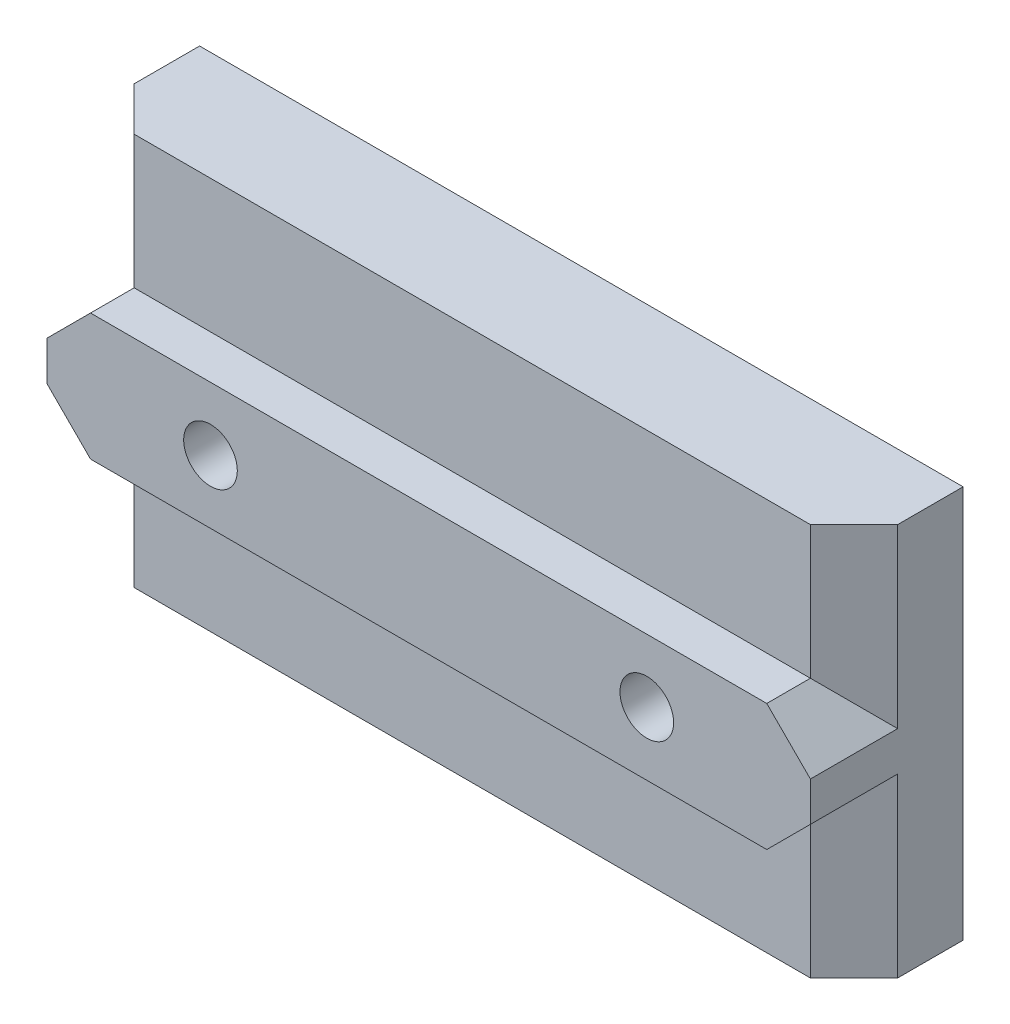
from build123d import *

# Parameters (mm, degrees)
SKETCH1_W                = 35
SKETCH1_H                = 18
BOSS_EXTRUDE1_DEPTH      = 8
SKETCH2_W                = 3
SKETCH2_H                = 6.1
CUT_EXTRUDE1_DEPTH       = 36
SKETCH3_W                = 3
SKETCH3_H                = 6.1
CUT_EXTRUDE2_DEPTH       = 36
M2_CLEARANCE_HOLE1_D     = 2.459
M2_CLEARANCE_HOLE1_DEPTH = 8
CHAMFER1_SIZE            = 0.2705
CHAMFER2_SIZE            = 2
SKETCH6_W                = 35
SKETCH6_H                = 1
CUT_EXTRUDE4_DEPTH       = 10


with BuildPart() as part:
    # Sketch1 → Boss-Extrude1 (new body)
    with BuildSketch(Plane.XY.offset(8)):
        Rectangle(SKETCH1_W, SKETCH1_H)
    extrude(amount=-BOSS_EXTRUDE1_DEPTH)

    # Sketch2 → Cut-Extrude1 (cut, through all)
    with BuildSketch(Plane.ZY.offset(17.5)):
        with Locations((6.5, 5.95)):
            Rectangle(SKETCH2_W, SKETCH2_H)
    extrude(amount=-CUT_EXTRUDE1_DEPTH, mode=Mode.SUBTRACT)

    # Sketch3 → Cut-Extrude2 (cut, through all)
    with BuildSketch(Plane.ZY.offset(17.5)):
        with Locations((6.5, -5.95)):
            Rectangle(SKETCH3_W, SKETCH3_H)
    extrude(amount=-CUT_EXTRUDE2_DEPTH, mode=Mode.SUBTRACT)

    # M2 Clearance Hole1
    with Locations(Plane.XY.offset(8)):
        with Locations((-10, 0), (10, 0)):
            Hole(M2_CLEARANCE_HOLE1_D / 2, depth=M2_CLEARANCE_HOLE1_DEPTH)

    # Chamfer1
    chamfer1_edges = [part.edges().sort_by_distance(p)[0] for p in [
        (11.2295, 0, 8),
        (11.2295, 0, 0),
        (-8.7705, 0, 8),
        (-8.7705, 0, 0),
    ]]
    chamfer(chamfer1_edges, length=CHAMFER1_SIZE)

    # Chamfer2
    chamfer2_edges = [part.edges().sort_by_distance(p)[0] for p in [
        (17.5, 5.95, 5),
        (17.5, 2.9, 6.5),
        (-17.5, 5.95, 5),
        (-17.5, 2.9, 6.5),
        (17.5, -5.95, 5),
        (17.5, -2.9, 6.5),
        (-17.5, -2.9, 6.5),
        (-17.5, -5.95, 5),
    ]]
    chamfer(chamfer2_edges, length=CHAMFER2_SIZE)

    # Sketch6 → Cut-Extrude4 (cut)
    with BuildSketch(Plane(origin=(0, 2.9, 0), x_dir=(1, 0, 0), z_dir=(0, 1, 0))):
        with Locations((0, -7.5)):
            Rectangle(SKETCH6_W, SKETCH6_H)
    extrude(amount=-CUT_EXTRUDE4_DEPTH, mode=Mode.SUBTRACT)


solid = part.part
